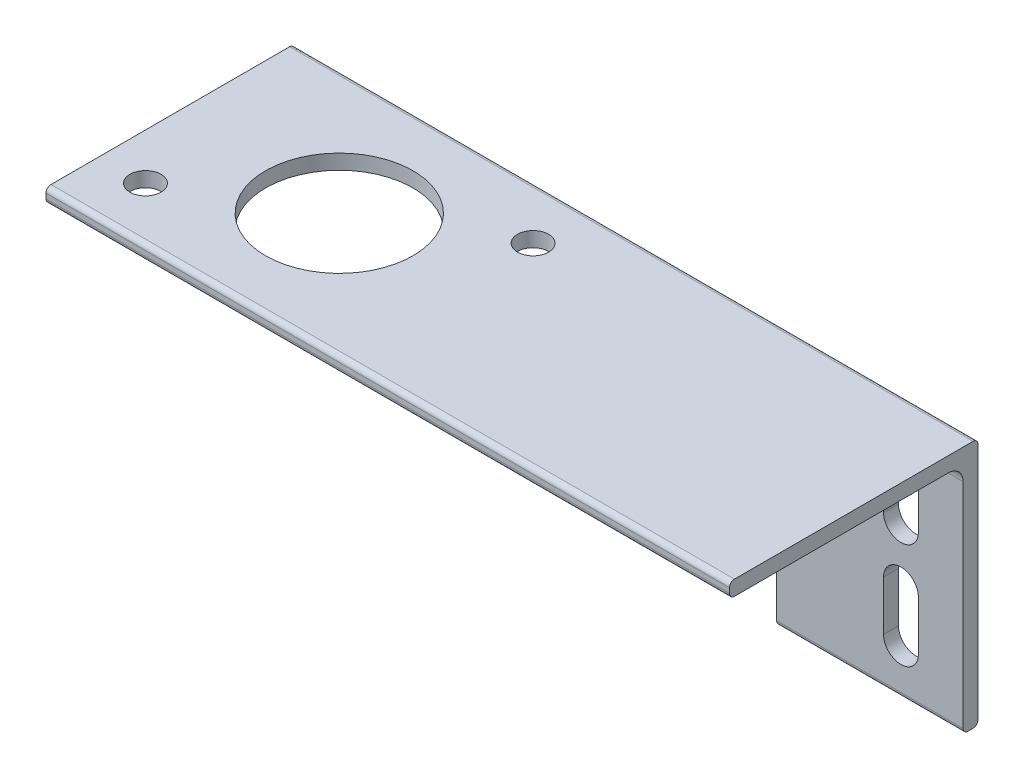
from build123d import *

# Parameters (mm, degrees)
BOSS_EXTRUDE1_DEPTH = 69.85
SKETCH2_R           = 7.5311
SKETCH2_R_2         = 1.5875
CUT_EXTRUDE1_DEPTH  = 26.4
CUT_EXTRUDE2_DEPTH  = 26.4
CUT_EXTRUDE3_DEPTH  = 26.4


with BuildPart() as part:
    # Sketch1 → Boss-Extrude1 (new body)
    with BuildSketch(Plane(origin=(0, 0, 0), x_dir=(0, 0, -1), z_dir=(1, 0, 0))):
        with BuildLine():
            Line((9.652, 11.176), (-11.176, 11.176))
            Line((-11.176, 11.176), (-12.192, 11.176))
            ThreePointArc((-12.192, 11.176), (-12.551210245, 11.324789755), (-12.7, 11.684))
            Line((-12.7, 11.684), (-12.7, 12.192))
            ThreePointArc((-12.7, 12.192), (-12.551210245, 12.551210245), (-12.192, 12.7))
            Line((-12.192, 12.7), (12.192, 12.7))
            ThreePointArc((12.192, 12.7), (12.551210245, 12.551210245), (12.7, 12.192))
            Line((12.7, 12.192), (12.7, -12.192))
            ThreePointArc((12.7, -12.192), (12.551210245, -12.551210245), (12.192, -12.7))
            Line((12.192, -12.7), (11.684, -12.7))
            ThreePointArc((11.684, -12.7), (11.324789755, -12.551210245), (11.176, -12.192))
            Line((11.176, -12.192), (11.176, -11.176))
            Line((11.176, -11.176), (11.176, 9.652))
            ThreePointArc((11.176, 9.652), (10.729630735, 10.729630735), (9.652, 11.176))
        make_face()
    extrude(amount=BOSS_EXTRUDE1_DEPTH)

    # Sketch2 → Cut-Extrude1 (cut, through all)
    with BuildSketch(Plane(origin=(0, 12.7, 0), x_dir=(1, 0, 0), z_dir=(0, 1, 0))):
        with Locations((17.272, 0)):
            Circle(SKETCH2_R)
        with Locations((29.829368355, 7.25)):
            Circle(SKETCH2_R_2)
        with Locations((4.714631645, -7.25)):
            Circle(SKETCH2_R_2)
    extrude(amount=-CUT_EXTRUDE1_DEPTH, mode=Mode.SUBTRACT)

    # Sketch3 → Cut-Extrude2 (cut, through all)
    with BuildSketch(Plane(origin=(0, 0, -12.7), x_dir=(-1, 0, 0), z_dir=(0, 0, -1))):
        with BuildLine():
            Line((-38.1, 10.084370729), (0, 10.084370729))
            ThreePointArc((0, 10.084370729), (12.7, -2.615629271), (0, -15.315629271))
            Line((0, -15.315629271), (-38.1, -15.315629271))
            Line((-38.1, -15.315629271), (-50.8, -15.315629271))
            Line((-50.8, -15.315629271), (-50.8, -2.615629271))
            ThreePointArc((-50.8, -2.615629271), (-47.080256121, 6.36462685), (-38.1, 10.084370729))
        make_face()
    extrude(amount=-CUT_EXTRUDE2_DEPTH, mode=Mode.SUBTRACT)

    # Sketch4 → Cut-Extrude3 (cut, through all)
    with BuildSketch(Plane(origin=(0, 0, -12.7), x_dir=(-1, 0, 0), z_dir=(0, 0, -1))):
        with BuildLine():
            Line((-65.278, -7.9375), (-65.278, -2.8575))
            ThreePointArc((-65.278, -2.8575), (-63.5, -1.0795), (-61.722, -2.8575))
            Line((-61.722, -2.8575), (-61.722, -7.9375))
            ThreePointArc((-61.722, -7.9375), (-63.5, -9.7155), (-65.278, -7.9375))
        make_face()
        with BuildLine():
            Line((-65.278, 2.8575), (-65.278, 7.9375))
            ThreePointArc((-65.278, 7.9375), (-63.5, 9.7155), (-61.722, 7.9375))
            Line((-61.722, 7.9375), (-61.722, 2.8575))
            ThreePointArc((-61.722, 2.8575), (-63.5, 1.0795), (-65.278, 2.8575))
        make_face()
    extrude(amount=-CUT_EXTRUDE3_DEPTH, mode=Mode.SUBTRACT)


solid = part.part
